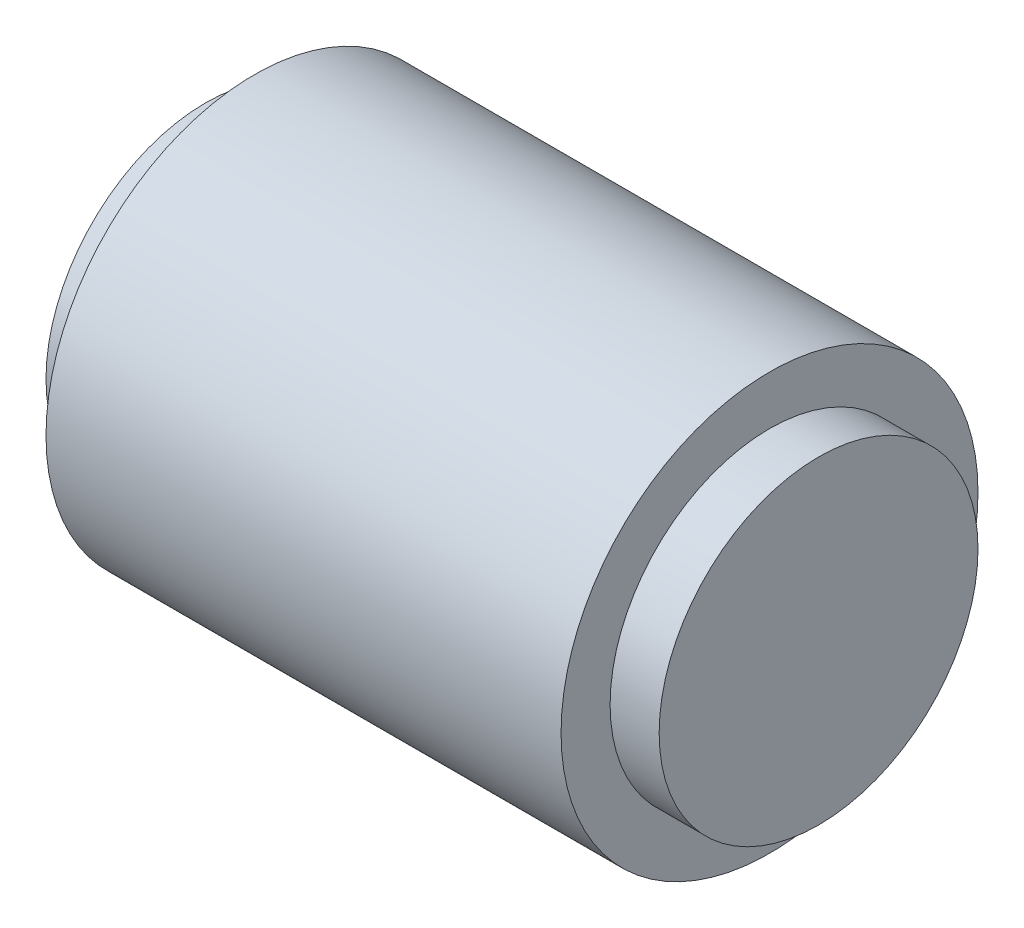
from build123d import *

# Parameters (mm, degrees)
ENL_V_MAT_EXTRU_1_REACH = 10.5
ESQUISSE2_R             = 4.7


with BuildPart() as part:
    # Esquisse1 → Révolution1 (revolve)
    with BuildSketch(Plane.XY, mode=Mode.PRIVATE) as r_volution1_sk:
        Polygon((-25, 0), (0, 0), (0, -6.5), (-2, -6.5), (-2, -8.5), (-23, -8.5), (-23, -6.5), (-25, -6.5), align=None)
    revolve(r_volution1_sk.sketch.rotate(Axis((35.066018426, 0, 0), (-1, 0, 0)), 270), axis=Axis((35.066018426, 0, 0), (-1, 0, 0)))  # turned: the seam where the file's is

    # Esquisse2 → Enlèv. mat.-Extru.1 (cut, up to next)
    with BuildSketch(Plane(origin=(0, 0, 0), x_dir=(1, 0, 0), z_dir=(0, 1, 0)), mode=Mode.PRIVATE) as enl_v_mat_extru_1_sk1:
        with Locations(Location((-12.5, 0, 0), (0, 0, 270))):  # turned: the seam where the file's is
            Circle(ESQUISSE2_R)
    enl_v_mat_extru_1_tool1 = extrude(enl_v_mat_extru_1_sk1.sketch, amount=-ENL_V_MAT_EXTRU_1_REACH, mode=Mode.PRIVATE) & part.part
    add(enl_v_mat_extru_1_tool1.solids().sort_by_distance((-12.5, 0, 0))[0], mode=Mode.SUBTRACT)


solid = part.part
